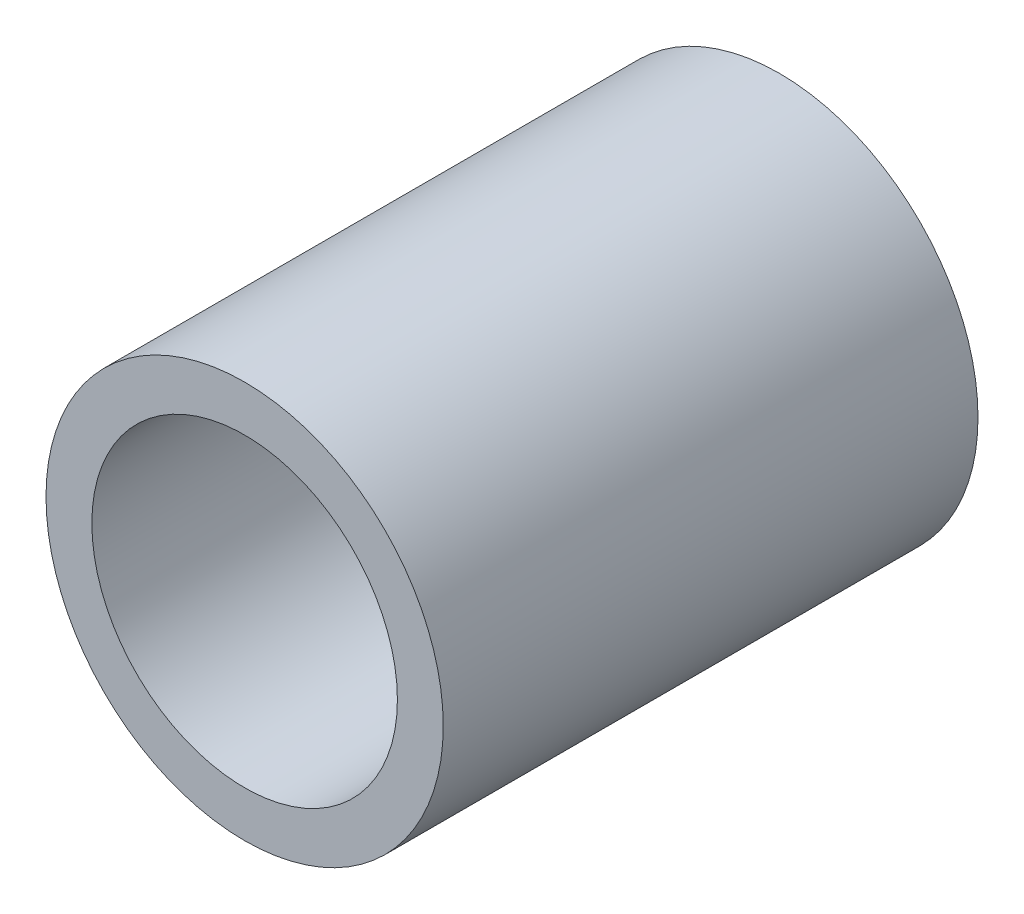
from build123d import *

# Parameters (mm, degrees)
SKETCH1_R           = 13
SKETCH1_R_2         = 10
BOSS_EXTRUDE1_DEPTH = 35


with BuildPart() as part:
    # Sketch1 → Boss-Extrude1 (new body)
    with BuildSketch(Plane.XY):
        Circle(SKETCH1_R)
        Circle(SKETCH1_R_2, mode=Mode.SUBTRACT)
    extrude(amount=BOSS_EXTRUDE1_DEPTH)


solid = part.part
